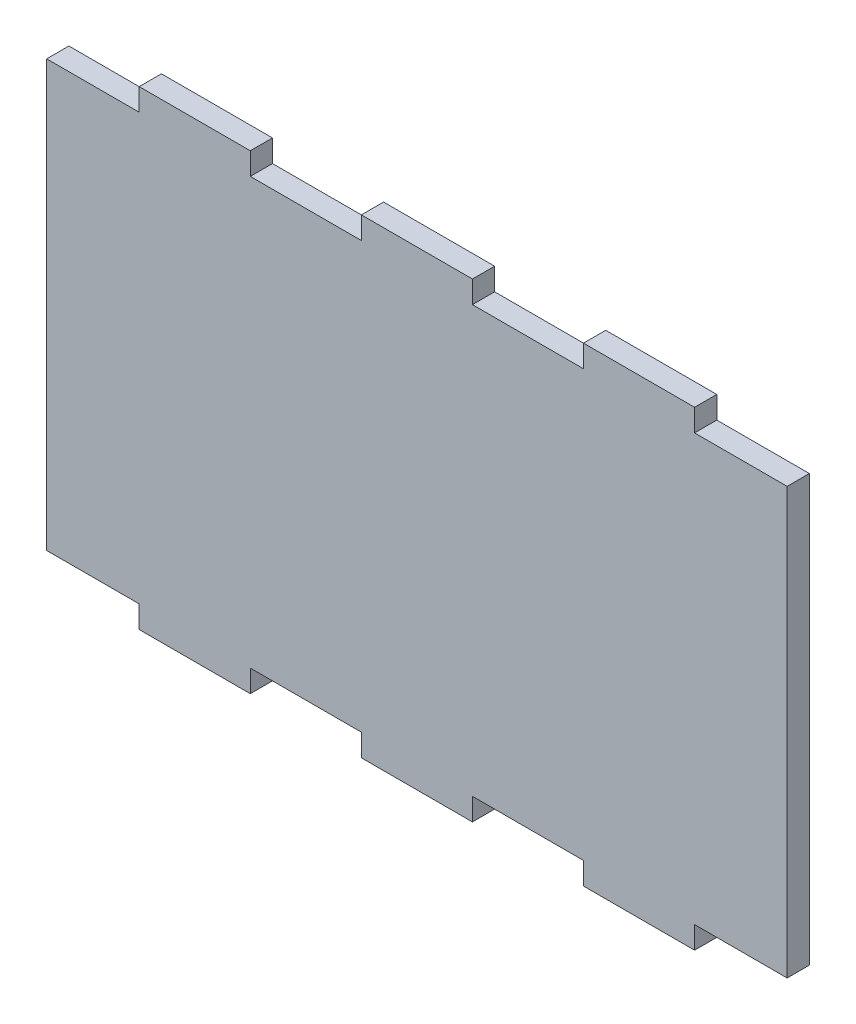
from build123d import *

# Parameters (mm, degrees)
SKETCH1_W           = 100
SKETCH1_H           = 63.5
BOSS_EXTRUDE1_DEPTH = 3
SKETCH2_W           = 12.5
SKETCH2_H           = 3
SKETCH2_W_2         = 15
CUT_EXTRUDE1_DEPTH  = 4


with BuildPart() as part:
    # Sketch1 → Boss-Extrude1 (new body)
    with BuildSketch(Plane.XY):
        Rectangle(SKETCH1_W, SKETCH1_H)
    extrude(amount=BOSS_EXTRUDE1_DEPTH)

    # Sketch2 → Cut-Extrude1 (cut, through all)
    with BuildSketch(Plane.XY.offset(3)):
        with Locations((-43.75, 30.25)):
            Rectangle(SKETCH2_W, SKETCH2_H)
        with Locations((-15, 30.25)):
            Rectangle(SKETCH2_W_2, SKETCH2_H)
        with Locations((15, 30.25)):
            Rectangle(SKETCH2_W_2, SKETCH2_H)
        with Locations((43.75, 30.25)):
            Rectangle(SKETCH2_W, SKETCH2_H)
    cut_extrude1 = extrude(amount=-CUT_EXTRUDE1_DEPTH, mode=Mode.SUBTRACT)

    # Mirror2: Cut-Extrude1 across plane
    add(cut_extrude1.mirror(Plane.ZX), mode=Mode.SUBTRACT)


solid = part.part
